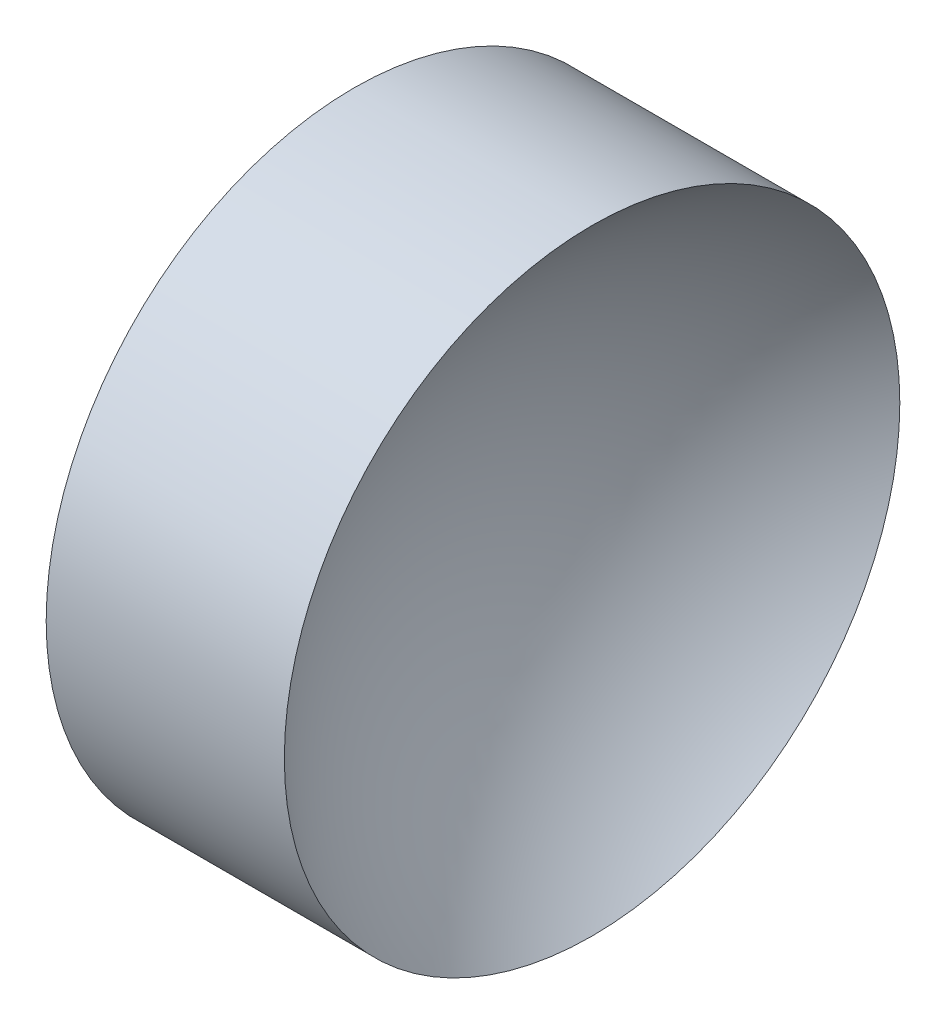
from build123d import *


with BuildPart() as part:
    # 草图1 → 旋转1 (revolve)
    with BuildSketch(Plane.XY, mode=Mode.PRIVATE) as revolve_1_sk:
        with BuildLine():
            Line((22.424232054, 13.031126091), (22.424232054, 18.031126091))
            Line((22.424232054, 18.031126091), (26.293804203, 18.031126091))
            ThreePointArc((26.293804203, 18.031126091), (24.546605656, 15.797661478), (23.924232054, 13.031126091))
            Line((23.924232054, 13.031126091), (22.424232054, 13.031126091))
        make_face()
    revolve(revolve_1_sk.sketch.rotate(Axis((21.505975118, 13.031126091, 0), (1, 0, 0)), 180), axis=Axis((21.505975118, 13.031126091, 0), (1, 0, 0)))  # turned: the seam where the file's is


solid = part.part
